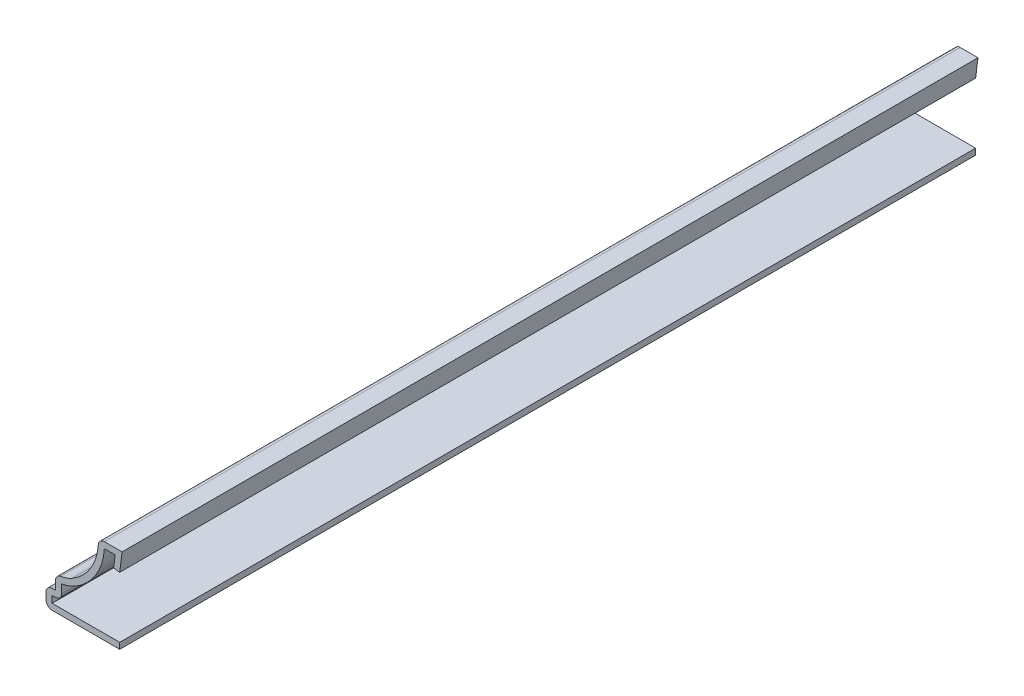
from build123d import *

# Parameters (mm, degrees)
EXTRUDE_THIN1_DEPTH = 142.875
FILLET1_R           = 1.016


with BuildPart() as part:
    # Sketch1 → Extrude-Thin1 (new body)
    with BuildSketch(Plane.XY):
        with BuildLine():
            Line((-0.396875, 11.137402345), (0, 14.2875))
            Line((0, 14.2875), (-3.96875, 14.2875))
            ThreePointArc((-3.96875, 14.2875), (-5.03336677, 9.671261516), (-8.352026926, 6.290498085))
            ThreePointArc((-8.352026926, 6.290498085), (-9.684272791, 5.742948706), (-11.1125, 5.55625))
            Line((-11.1125, 5.55625), (-11.1125, 3.175))
            Line((-11.1125, 3.175), (-12.7, 3.175))
            Line((-12.7, 3.175), (-12.7, 0))
            Line((-12.7, 0), (-0.396875, 0))
            Line((-0.396875, 0), (-0.396875, 1.016))
            Line((-0.396875, 1.016), (-11.684, 1.016))
            Line((-11.684, 1.016), (-11.684, 2.159))
            Line((-11.684, 2.159), (-10.0965, 2.159))
            Line((-10.0965, 2.159), (-10.0965, 4.619256276))
            ThreePointArc((-10.0965, 4.619256276), (-8.935783532, 4.911179537), (-7.847254707, 5.408760591))
            ThreePointArc((-7.847254707, 5.408760591), (-4.411092734, 8.723027869), (-2.960927924, 13.2715))
            Line((-2.960927924, 13.2715), (-1.152035714, 13.2715))
            Line((-1.152035714, 13.2715), (-1.40490625, 11.264402345))
            Line((-1.40490625, 11.264402345), (-0.396875, 11.137402345))
        make_face()
    extrude(amount=-EXTRUDE_THIN1_DEPTH)

    # Fillet1
    fillet1_edges = [part.edges().sort_by_distance(p)[0] for p in [
        (-10.0965, 2.159, -71.4375),
        (-12.7, 0, -71.4375),
        (-12.7, 3.175, -71.4375),
        (-11.1125, 5.55625, -71.4375),
        (-3.96875, 14.2875, -71.4375),
    ]]
    fillet(fillet1_edges, radius=FILLET1_R)


solid = part.part
